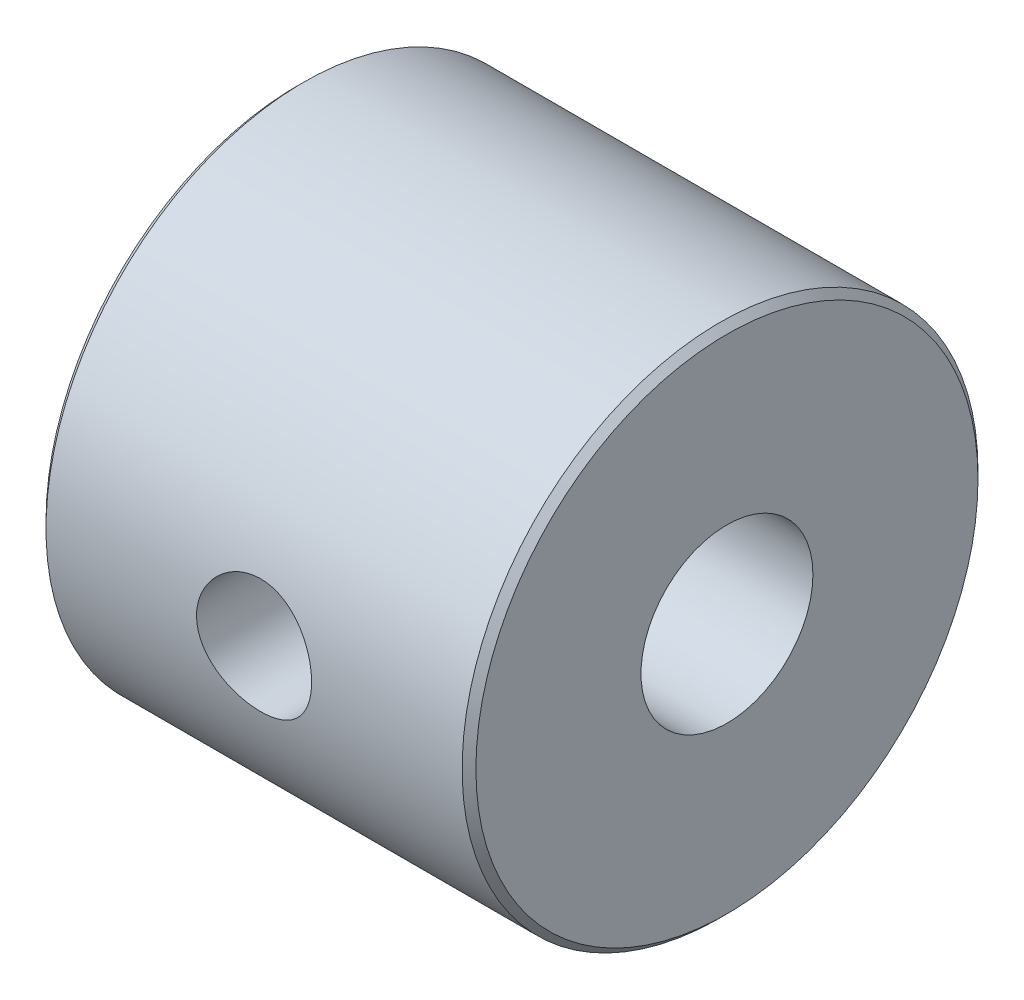
from build123d import *

# Parameters (mm, degrees)
SKETCH1_R           = 19.05
SKETCH1_R_2         = 6.35
BOSS_EXTRUDE1_DEPTH = 31.75
SKETCH2_R           = 4.25
CUT_EXTRUDE1_DEPTH  = 42.639734629
SKETCH2_6_R         = 2.5
CUT_EXTRUDE3_DEPTH  = 42.639734797
CHAMFER1_SIZE       = 0.508


with BuildPart() as part:
    # Sketch1 → Boss-Extrude1 (new body)
    with BuildSketch(Plane(origin=(0, 0, 0), x_dir=(0, 0, -1), z_dir=(1, 0, 0))):
        Circle(SKETCH1_R)
        Circle(SKETCH1_R_2, mode=Mode.SUBTRACT)
    extrude(amount=BOSS_EXTRUDE1_DEPTH)

    # Sketch2 → Cut-Extrude1 (cut, through all)
    with BuildSketch(Plane.XY):
        with Locations((15.875, 0)):
            Circle(SKETCH2_R)
    extrude(amount=CUT_EXTRUDE1_DEPTH, mode=Mode.SUBTRACT)

    # Sketch2_6 → Cut-Extrude3 (cut, through all)
    with BuildSketch(Plane.XY):
        with Locations((15.875, 0)):
            Circle(SKETCH2_6_R)
    extrude(amount=-CUT_EXTRUDE3_DEPTH, mode=Mode.SUBTRACT)

    # Chamfer1
    chamfer1_edges = [part.edges().sort_by_distance(p)[0] for p in [
        (31.75, 0, 19.05),
        (0, 0, 19.05),
    ]]
    chamfer(chamfer1_edges, length=CHAMFER1_SIZE)


solid = part.part
